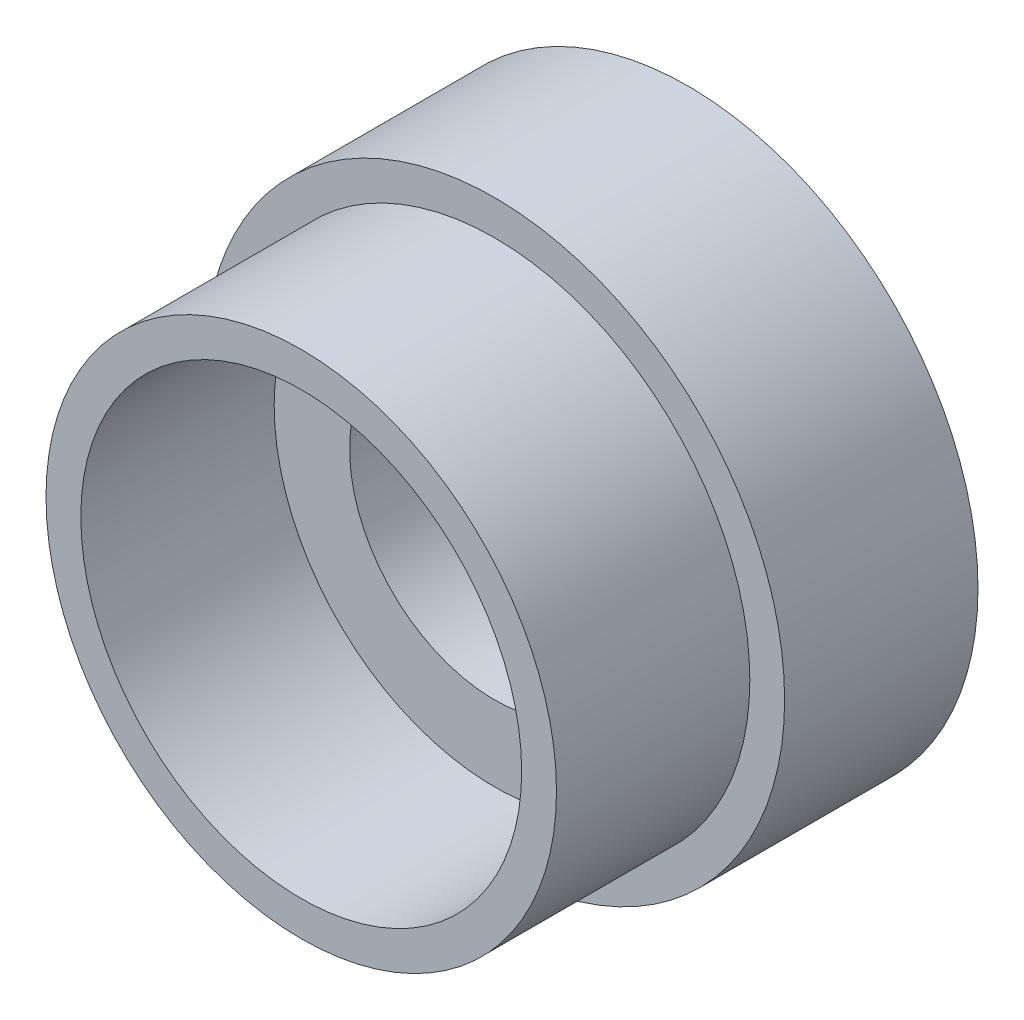
from build123d import *

# Parameters (mm, degrees)
SKETCH1_R           = 9.525
SKETCH1_R_2         = 4.7625
BOSS_EXTRUDE1_DEPTH = 6.35
SKETCH2_R           = 8.382
SKETCH2_R_2         = 7.239
BOSS_EXTRUDE3_DEPTH = 6.35


with BuildPart() as part:
    # Sketch1 → Boss-Extrude1 (new body)
    with BuildSketch(Plane.XY):
        Circle(SKETCH1_R)
        Circle(SKETCH1_R_2, mode=Mode.SUBTRACT)
    extrude(amount=BOSS_EXTRUDE1_DEPTH)

    # Sketch2 → Boss-Extrude3 (add)
    with BuildSketch(Plane.XY.offset(6.35)):
        Circle(SKETCH2_R)
        Circle(SKETCH2_R_2, mode=Mode.SUBTRACT)
    extrude(amount=BOSS_EXTRUDE3_DEPTH)


solid = part.part
